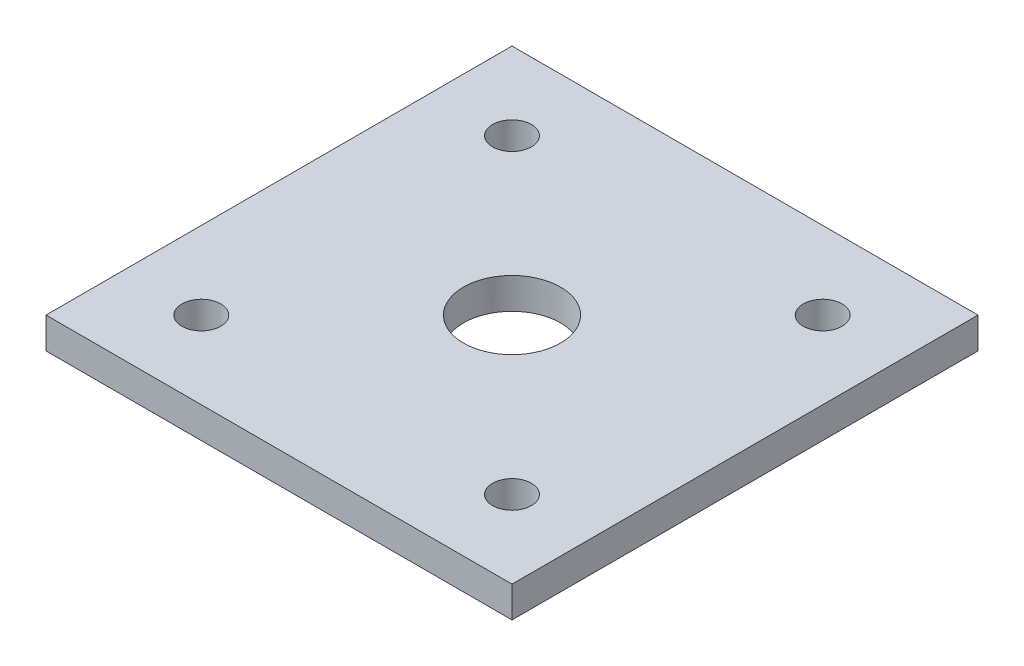
from build123d import *

# Parameters (mm, degrees)
SKETCH1_W            = 120
SKETCH1_H            = 120
BOSS_EXTRUDE1_DEPTH  = 8
SKETCH2_R            = 12.5
CUT_EXTRUDE1_DEPTH   = 10
SKETCH3_R            = 5
CUT_EXTRUDE2_DEPTH   = 10
LPATTERN1_COUNT      = 2
LPATTERN1_PITCH      = 80
LPATTERN1_COUNT_DIR2 = 2
LPATTERN1_PITCH_DIR2 = 80


with BuildPart() as part:
    # Sketch1 → Boss-Extrude1 (new body)
    with BuildSketch(Plane(origin=(0, 0, 0), x_dir=(1, 0, 0), z_dir=(0, 1, 0))):
        Rectangle(SKETCH1_W, SKETCH1_H)
    extrude(amount=BOSS_EXTRUDE1_DEPTH)

    # Sketch2 → Cut-Extrude1 (cut)
    with BuildSketch(Plane(origin=(0, 8, 0), x_dir=(1, 0, 0), z_dir=(0, 1, 0))):
        Circle(SKETCH2_R)
    extrude(amount=-CUT_EXTRUDE1_DEPTH, mode=Mode.SUBTRACT)

    # Sketch3 → Cut-Extrude2 (cut)
    with BuildSketch(Plane.XZ):
        with Locations((-40, -40)):
            Circle(SKETCH3_R)
    cut_extrude2 = extrude(amount=-CUT_EXTRUDE2_DEPTH, mode=Mode.SUBTRACT)

    # LPattern1: Cut-Extrude2 2 × 2
    with Locations(*[(j * LPATTERN1_PITCH_DIR2, 0, i * LPATTERN1_PITCH) for i in range(LPATTERN1_COUNT) for j in range(LPATTERN1_COUNT_DIR2) if (i, j) != (0, 0)]):
        add(cut_extrude2, mode=Mode.SUBTRACT)


solid = part.part
